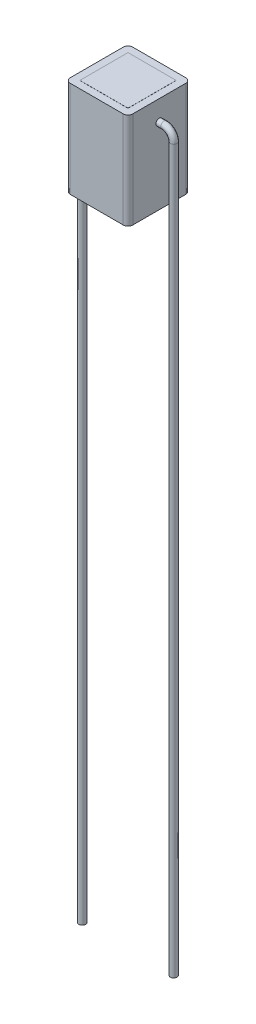
from build123d import *

# Parameters (mm, degrees)
SKETCH1_W                = 6.5
SKETCH1_H                = 6.5
BOSS_EXTRUDE1_DEPTH      = 10
SKETCH2_W                = 5
SKETCH2_H                = 5
BOSS_EXTRUDE2_DEPTH      = 10.01
BOSS_EXTRUDE2_DEPTH_BACK = 0.01
SWEEP2_PROFILE_R         = 0.35
FILLET2_R                = 0.5


with BuildPart() as part:
    # Sketch1 → Boss-Extrude1 (new body)
    with BuildSketch(Plane(origin=(0, 0, 0), x_dir=(1, 0, 0), z_dir=(0, 1, 0))):
        Rectangle(SKETCH1_W, SKETCH1_H)
    boss_extrude1 = extrude(amount=BOSS_EXTRUDE1_DEPTH)

    # Sketch2 → Boss-Extrude2 (add, two sides)
    with BuildSketch(Plane(origin=(0, 0, 0), x_dir=(1, 0, 0), z_dir=(0, 1, 0))) as boss_extrude2_sk:
        Rectangle(SKETCH2_W, SKETCH2_H)
    extrude(amount=BOSS_EXTRUDE2_DEPTH)
    extrude(boss_extrude2_sk.sketch, amount=-BOSS_EXTRUDE2_DEPTH_BACK)

    # Sweep2: sweep along a path in Sketch4
    with BuildLine(Plane.XY) as sweep2_path:
        Line((3.2, 7.882896733), (3.25, 7.882896733))
        Line((3.25, 7.882896733), (3.75, 7.882896733))
        ThreePointArc((3.75, 7.882896733), (4.457106781, 7.590003514), (4.75, 6.882896733))
        Line((4.75, 6.882896733), (4.75, -68.117103267))
    # Sweep2 profile (on start of the path) → Sweep2 (sweep)
    with BuildSketch(Plane(origin=(3.2, 7.882896733, 0), x_dir=(0, 0, 1), z_dir=(1, 0, 0))):
        Circle(SWEEP2_PROFILE_R)
    sweep2 = sweep(path=sweep2_path.line)

    # Mirror1: Boss-Extrude1, Sweep2 across plane
    add(boss_extrude1.mirror(Plane(origin=(0, 0, 0), x_dir=(0, 0, 1), z_dir=(1, 0, 0))))
    add(sweep2.mirror(Plane(origin=(0, 0, 0), x_dir=(0, 0, 1), z_dir=(1, 0, 0))))

    # Fillet2
    fillet2_edges = [part.edges().sort_by_distance(p)[0] for p in [
        (3.25, 5, 3.25),
        (-3.25, 5, 3.25),
        (-3.25, 5, -3.25),
        (3.25, 5, -3.25),
    ]]
    fillet(fillet2_edges, radius=FILLET2_R)


solid = part.part
